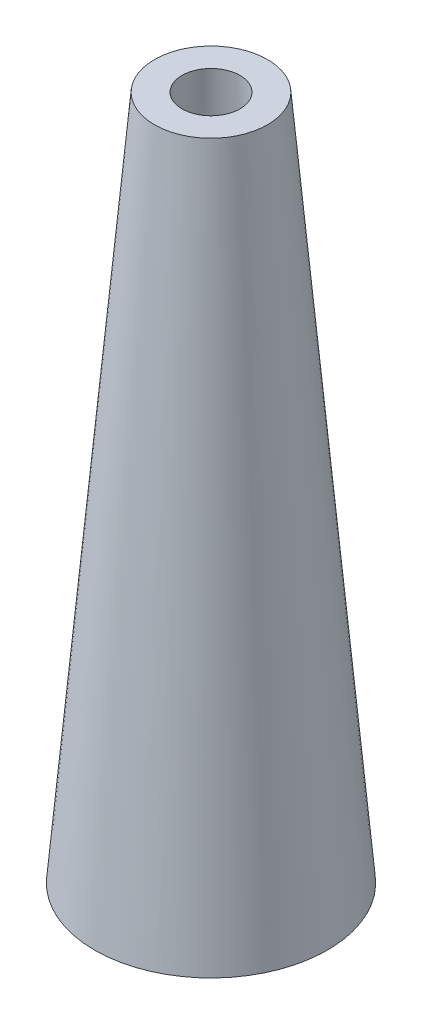
from build123d import *

# Parameters (mm, degrees)
IZIM1_R                     = 1.7
Y_KSEKLIK_EKSTR_ZYON1_DEPTH = 10
Y_KSEKLIK_EKSTR_ZYON1_TAPER = 5
IZIM2_R                     = 1.122825905
KES_EKSTR_ZYON1_DEPTH       = 10
KES_EKSTR_ZYON1_TAPER       = 4
IZIM3_R                     = 1.122825905
IZIM3_R_2                   = 0.19962026
IZIM3_R_3                   = 0.196792851
IZIM3_R_4                   = 0.203205658
IZIM3_R_5                   = 0.197119951
Y_KSEKLIK_EKSTR_ZYON3_DEPTH = 1
IZIM5_R                     = 0.197735833
IZIM5_R_2                   = 0.2
KES_EKSTR_ZYON2_DEPTH       = 1
IZIM6_R                     = 0.196695493
KES_EKSTR_ZYON3_DEPTH       = 1


with BuildPart() as part:
    # Çizim1 → Yükseklik-Ekstrüzyon1 (new body)
    with BuildSketch(Plane(origin=(0, 0, 0), x_dir=(1, 0, 0), z_dir=(0, 1, 0))):
        Circle(IZIM1_R)
    extrude(amount=Y_KSEKLIK_EKSTR_ZYON1_DEPTH, taper=Y_KSEKLIK_EKSTR_ZYON1_TAPER)

    # Çizim2 → Kes-Ekstrüzyon1 (cut)
    with BuildSketch(Plane.XZ):
        Circle(IZIM2_R)
    extrude(amount=-KES_EKSTR_ZYON1_DEPTH, taper=KES_EKSTR_ZYON1_TAPER, mode=Mode.SUBTRACT)

    # Çizim3 → Yükseklik-Ekstrüzyon3 (add)
    with BuildSketch(Plane(origin=(0, 0, 0), x_dir=(-1, 0, 0), z_dir=(0, -1, 0))):
        Circle(IZIM3_R)
        with Locations((-0.353553391, -0.353553391)):
            Circle(IZIM3_R_2, mode=Mode.SUBTRACT)
        with Locations((-0.353553391, 0.353553391)):
            Circle(IZIM3_R_3, mode=Mode.SUBTRACT)
        with Locations((0.353553391, 0.353553391)):
            Circle(IZIM3_R_4, mode=Mode.SUBTRACT)
        with Locations((0.353553391, -0.353553391)):
            Circle(IZIM3_R_5, mode=Mode.SUBTRACT)
    extrude(amount=-Y_KSEKLIK_EKSTR_ZYON3_DEPTH)

    # Çizim5 → Kes-Ekstrüzyon2 (cut)
    with BuildSketch(Plane.XZ):
        with Locations((0.8, 0)):
            Circle(IZIM5_R)
        with Locations((-0.8, 0)):
            Circle(IZIM5_R_2)
        with Locations((0, -0.8)):
            Circle(IZIM5_R)
        with Locations((0, 0.8)):
            Circle(IZIM5_R_2)
    extrude(amount=-KES_EKSTR_ZYON2_DEPTH, mode=Mode.SUBTRACT)

    # Çizim6 → Kes-Ekstrüzyon3 (cut)
    with BuildSketch(Plane.XZ):
        Circle(IZIM6_R)
    extrude(amount=-KES_EKSTR_ZYON3_DEPTH, mode=Mode.SUBTRACT)


solid = part.part
